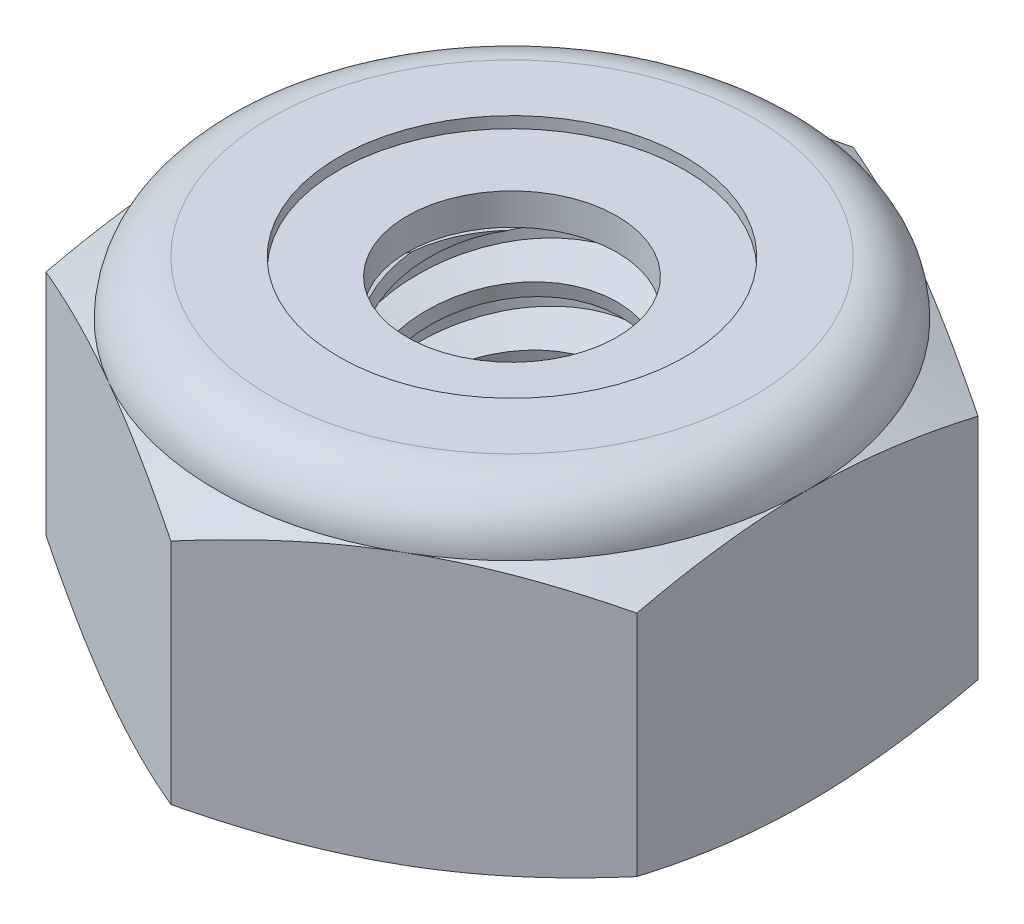
from build123d import *

# Parameters (mm, degrees)
EXTRUDE1_DEPTH       = 4.365625
SKETCH2_W            = 1.7526
SKETCH2_H            = 4.365625
LPATTERN1_COUNT      = 6
LPATTERN1_PITCH      = 0.79375
LPATTERN1_COUNT_DIR2 = 2
LPATTERN1_PITCH_DIR2 = 0.79375


with BuildPart() as part:
    # Sketch1 → Extrude1 (new body)
    with BuildSketch(Plane(origin=(0, 0, 0), x_dir=(1, 0, 0), z_dir=(0, 1, 0))):
        Polygon((0, 4.582717762), (-3.96875, 2.291358881), (-3.96875, -2.291358881), (0, -4.582717762), (3.96875, -2.291358881), (3.96875, 2.291358881), align=None)
    extrude(amount=EXTRUDE1_DEPTH)

    # Sketch4 → Cut-Revolve2 (revolve, cut)
    with BuildSketch(Plane(origin=(0, 0, 0), x_dir=(0, 0, -1), z_dir=(1, 0, 0))):
        Polygon((0, 4.365625), (1.7526, 4.365625), (1.410275607, 4.205996514), (1.410275607, 0.159628486), (1.7526, 0), (0, 0), align=None)
    revolve(axis=Axis((0, 4.365625, 0), (0, 1, 0)), mode=Mode.SUBTRACT)


with BuildPart() as body_2:
    # Sketch2 → Revolve1 (revolve)
    with BuildSketch(Plane(origin=(0, 0, 0), x_dir=(0, 0, -1), z_dir=(1, 0, 0))):
        with Locations((0.8763, 2.1828125)):
            Rectangle(SKETCH2_W, SKETCH2_H)
    revolve(axis=Axis((0, -1.7526, 0), (0, 1, 0)))

    # Sketch3 → Cut-Revolve1 (revolve, cut)
    with BuildSketch(Plane(origin=(0, 0, 0), x_dir=(0, 0, -1), z_dir=(1, 0, 0))):
        Polygon((1.774513192, 4.268856346), (1.927905533, 3.591475768), (1.454101991, 3.7385105), (1.410275607, 3.932047808), align=None)
    cut_revolve1 = revolve(axis=Axis((0, 4.365625, 0.193538035), (0, -0.9753061185369931, -0.22085736379913792)), mode=Mode.SUBTRACT)

    # LPattern1: Cut-Revolve1 6 × 2
    with Locations(*[Vector(0, -1, 0) * (i * LPATTERN1_PITCH) + Vector(0, 1, 0) * (j * LPATTERN1_PITCH_DIR2) for i in range(LPATTERN1_COUNT) for j in range(LPATTERN1_COUNT_DIR2) if (i, j) != (0, 0)]):
        add(cut_revolve1, mode=Mode.SUBTRACT)


with BuildPart() as part_1:
    add(part.part)

    # Combine1: cut body 2
    add(body_2.part, mode=Mode.SUBTRACT)

    # Sketch5 → Cut-Revolve3 (revolve, cut)
    with BuildSketch(Plane(origin=(0, 0, 0), x_dir=(0, 0, -1), z_dir=(1, 0, 0))):
        with BuildLine():
            Line((0, 0), (3.96875, 0))
            Line((3.96875, 0), (4.582717762, 0.286297869))
            Line((4.582717762, 0.286297869), (4.582717762, 3.351722964))
            Line((4.582717762, 3.351722964), (3.96875, 3.638020833))
            ThreePointArc((3.96875, 3.638020833), (3.755639674, 4.152514674), (3.241145833, 4.365625))
            Line((3.241145833, 4.365625), (3.241145833, 5.635625))
            Line((3.241145833, 5.635625), (5.852717762, 5.635625))
            Line((5.852717762, 5.635625), (5.852717762, -1.27))
            Line((5.852717762, -1.27), (0, -1.27))
            Line((0, -1.27), (0, 0))
        make_face()
    revolve(axis=Axis((0, 0, 0), (0, 1, 0)), mode=Mode.SUBTRACT)

    # Sketch6 → Cut-Revolve4 (revolve, cut)
    with BuildSketch(Plane(origin=(0, 0, 0), x_dir=(0, 0, -1), z_dir=(1, 0, 0))):
        with BuildLine():
            Line((0, 3.638020833), (3.81635, 3.638020833))
            ThreePointArc((3.81635, 3.638020833), (3.6478766, 4.0447516), (3.241145833, 4.213225))
            Line((3.241145833, 4.213225), (2.32571072, 4.213225))
            Line((2.32571072, 4.213225), (2.32571072, 5.635625))
            Line((2.32571072, 5.635625), (0, 5.635625))
            Line((0, 5.635625), (0, 3.638020833))
        make_face()
    revolve(axis=Axis((0, 5.635625, 0), (0, 1, 0)), mode=Mode.SUBTRACT)


with BuildPart() as body_2_2:
    # Sketch7 → Revolve2 (revolve)
    with BuildSketch(Plane(origin=(0, 0, 0), x_dir=(0, 0, -1), z_dir=(1, 0, 0))):
        with BuildLine():
            Line((1.410275607, 3.714220833), (3.734297654, 3.714220833))
            ThreePointArc((3.734297654, 3.714220833), (3.565938876, 4.016854092), (3.241145833, 4.137025))
            Line((3.241145833, 4.137025), (1.410275607, 4.137025))
            Line((1.410275607, 4.137025), (1.410275607, 3.714220833))
        make_face()
    revolve(axis=Axis((0, 3.714220833, 0), (0, 1, 0)))


solid = Compound([part_1.part, body_2_2.part])
